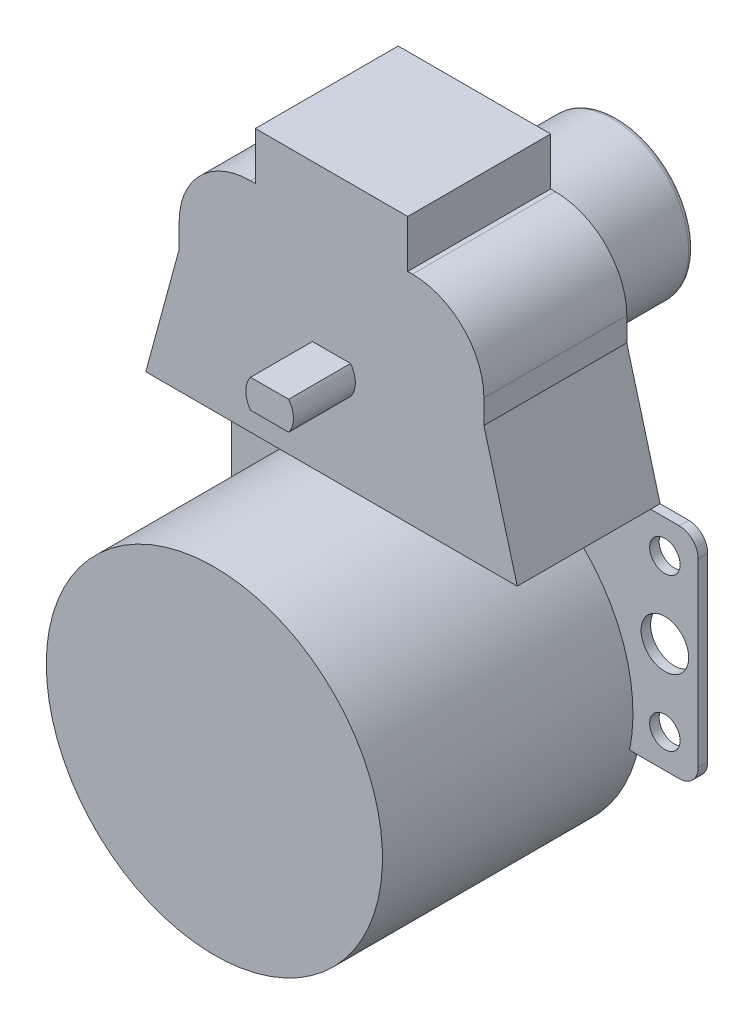
from build123d import *

# Parameters (mm, degrees)
SKETCH1_R           = 8
BOSS_EXTRUDE1_DEPTH = 13
SKETCH2_R           = 8.75
BOSS_EXTRUDE2_DEPTH = 2
SKETCH3_W           = 49
SKETCH3_H           = 62.5
BOSS_EXTRUDE3_DEPTH = 15
SKETCH4_R           = 17.65
BOSS_EXTRUDE4_DEPTH = 27.3
BOSS_EXTRUDE6_DEPTH = 36.5
SKETCH7_W           = 81.110714311
SKETCH7_H           = 82.460514398
CUT_EXTRUDE1_DEPTH  = 31
CUT_EXTRUDE2_DEPTH  = 14
SKETCH9_R           = 2.5
CUT_EXTRUDE4_DEPTH  = 17
SKETCH10_R          = 1.6
CUT_EXTRUDE5_DEPTH  = 17
FILLET1_R           = 0.5
SKETCH11_W          = 6
SKETCH11_H          = 2.1
CUT_EXTRUDE6_DEPTH  = 12


with BuildPart() as part:
    # Sketch1 → Boss-Extrude1 (new body)
    with BuildSketch(Plane.XY):
        Circle(SKETCH1_R)
    extrude(amount=BOSS_EXTRUDE1_DEPTH)

    # Sketch2 → Boss-Extrude2 (add)
    with BuildSketch(Plane.XY.offset(13)):
        Circle(SKETCH2_R)
    extrude(amount=BOSS_EXTRUDE2_DEPTH)

    # Sketch3 → Boss-Extrude3 (add)
    with BuildSketch(Plane.XY.offset(15)):
        with Locations((0, -13.38)):
            Rectangle(SKETCH3_W, SKETCH3_H)
    extrude(amount=BOSS_EXTRUDE3_DEPTH)

    # Sketch4 → Boss-Extrude4 (add)
    with BuildSketch(Plane(origin=(0, 0, 15), x_dir=(-1, 0, 0), z_dir=(0, 0, -1))):
        with Locations((0, -29.5)):
            Circle(SKETCH4_R)
    extrude(amount=-BOSS_EXTRUDE4_DEPTH)

    # Sketch6 → Boss-Extrude6 (add)
    with BuildSketch(Plane(origin=(0, 0, 0), x_dir=(-1, 0, 0), z_dir=(0, 0, -1))):
        with BuildLine():
            Line((2, 1.5), (-2, 1.5))
            ThreePointArc((-2, 1.5), (-2.5, 0), (-2, -1.5))
            Line((-2, -1.5), (2, -1.5))
            ThreePointArc((2, -1.5), (2.371708245, -0.790569415), (2.5, 0))
            ThreePointArc((2.5, 0), (2.371708245, 0.790569415), (2, 1.5))
        make_face()
    extrude(amount=-BOSS_EXTRUDE6_DEPTH)

    # Sketch7 → Cut-Extrude1 (cut, through all)
    with BuildSketch(Plane.XY.offset(30)):
        with Locations((0.873030834, -13.704939381)):
            Rectangle(SKETCH7_W, SKETCH7_H)
        with BuildLine():
            Line((-8, 17.87), (8, 17.87))
            Line((8, 17.87), (8, 12.87))
            Line((8, 12.87), (8.5, 12.87))
            ThreePointArc((8.5, 12.87), (13.803300859, 10.673300859), (16, 5.37))
            Line((16, 5.37), (16, 2.87))
            Line((16, 2.87), (19.5, -10))
            Line((19.5, -10), (22.5, -10))
            ThreePointArc((22.5, -10), (23.914213562, -10.585786438), (24.5, -12))
            Line((24.5, -12), (24.5, -31))
            ThreePointArc((24.5, -31), (23.914213562, -32.414213562), (22.5, -33))
            Line((22.5, -33), (17.299494212, -33))
            ThreePointArc((17.299494212, -33), (0, -47.15), (-17.299494212, -33))
            Line((-17.299494212, -33), (-22.5, -33))
            ThreePointArc((-22.5, -33), (-23.914213562, -32.414213562), (-24.5, -31))
            Line((-24.5, -31), (-24.5, -12))
            ThreePointArc((-24.5, -12), (-23.914213562, -10.585786438), (-22.5, -10))
            Line((-22.5, -10), (-19.5, -10))
            Line((-19.5, -10), (-16, 2.87))
            Line((-16, 2.87), (-16, 5.37))
            ThreePointArc((-16, 5.37), (-13.803300859, 10.673300859), (-8.5, 12.87))
            Line((-8.5, 12.87), (-8, 12.87))
            Line((-8, 12.87), (-8, 17.87))
        make_face(mode=Mode.SUBTRACT)
    extrude(amount=-CUT_EXTRUDE1_DEPTH, mode=Mode.SUBTRACT)

    # Sketch8 → Cut-Extrude2 (cut)
    with BuildSketch(Plane.XY.offset(30)):
        with BuildLine():
            Line((-17.299494212, -33), (-22.5, -33))
            ThreePointArc((-22.5, -33), (-23.914213562, -32.414213562), (-24.5, -31))
            Line((-24.5, -31), (-24.5, -12))
            ThreePointArc((-24.5, -12), (-23.914213562, -10.585786438), (-22.5, -10))
            Line((-22.5, -10), (22.5, -10))
            ThreePointArc((22.5, -10), (23.914213562, -10.585786438), (24.5, -12))
            Line((24.5, -12), (24.5, -31))
            ThreePointArc((24.5, -31), (23.914213562, -32.414213562), (22.5, -33))
            Line((22.5, -33), (17.299494212, -33))
            ThreePointArc((17.299494212, -33), (0, -11.85), (-17.299494212, -33))
        make_face()
    extrude(amount=-CUT_EXTRUDE2_DEPTH, mode=Mode.SUBTRACT)

    # Sketch9 → Cut-Extrude4 (cut, through all)
    with BuildSketch(Plane.XY.offset(16)):
        with Locations((-21, -21.5)):
            Circle(SKETCH9_R)
        with Locations((21, -21.5)):
            Circle(SKETCH9_R)
    extrude(amount=-CUT_EXTRUDE4_DEPTH, mode=Mode.SUBTRACT)

    # Sketch10 → Cut-Extrude5 (cut, through all)
    with BuildSketch(Plane.XY.offset(16)):
        with Locations((-21, -13.5)):
            Circle(SKETCH10_R)
        with Locations((21, -13.5)):
            Circle(SKETCH10_R)
        with Locations((21, -29.5)):
            Circle(SKETCH10_R)
        with Locations((-21, -29.5)):
            Circle(SKETCH10_R)
    extrude(amount=-CUT_EXTRUDE5_DEPTH, mode=Mode.SUBTRACT)

    # Fillet1
    fillet1_edges = [part.edges().sort_by_distance(p)[0] for p in [
        (-8, 0, 0),
    ]]
    fillet(fillet1_edges, radius=FILLET1_R)

    # Sketch11 → Cut-Extrude6 (cut)
    with BuildSketch(Plane(origin=(0, 0, 0), x_dir=(-1, 0, 0), z_dir=(0, 0, -1))):
        Rectangle(SKETCH11_W, SKETCH11_H)
    extrude(amount=-CUT_EXTRUDE6_DEPTH, mode=Mode.SUBTRACT)


solid = part.part
